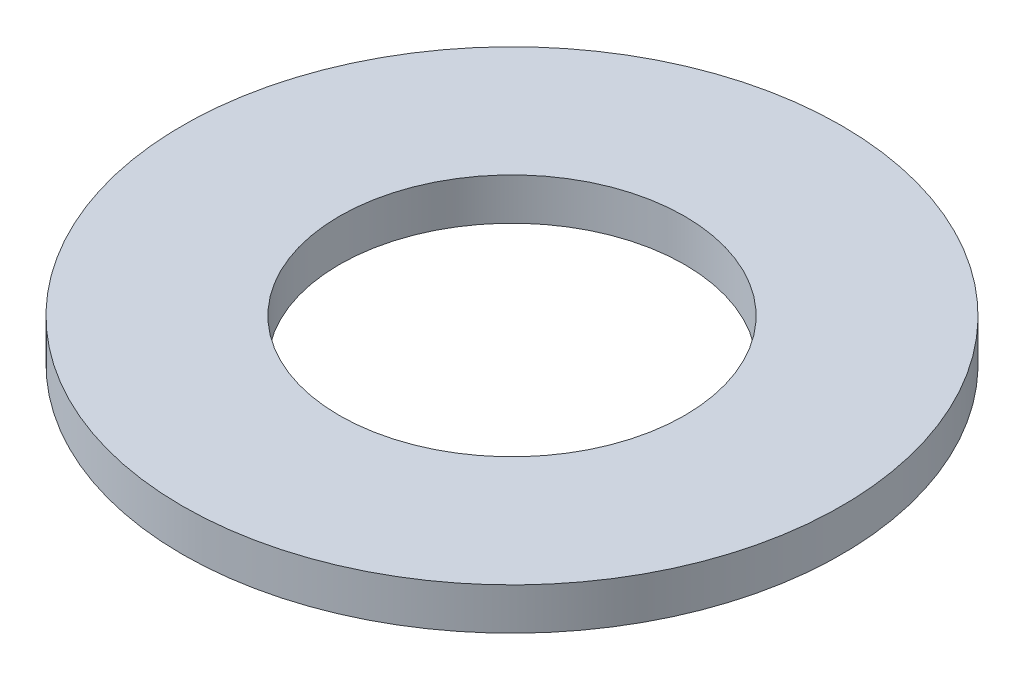
from build123d import *

# Parameters (mm, degrees)
SKETCH1_R           = 7.875
SKETCH1_R_2         = 4.125
BOSS_EXTRUDE1_DEPTH = 1


with BuildPart() as part:
    # Sketch1 → Boss-Extrude1 (new body)
    with BuildSketch(Plane(origin=(0, 0, 0), x_dir=(1, 0, 0), z_dir=(0, 1, 0))):
        Circle(SKETCH1_R)
        Circle(SKETCH1_R_2, mode=Mode.SUBTRACT)
    extrude(amount=BOSS_EXTRUDE1_DEPTH)


solid = part.part
